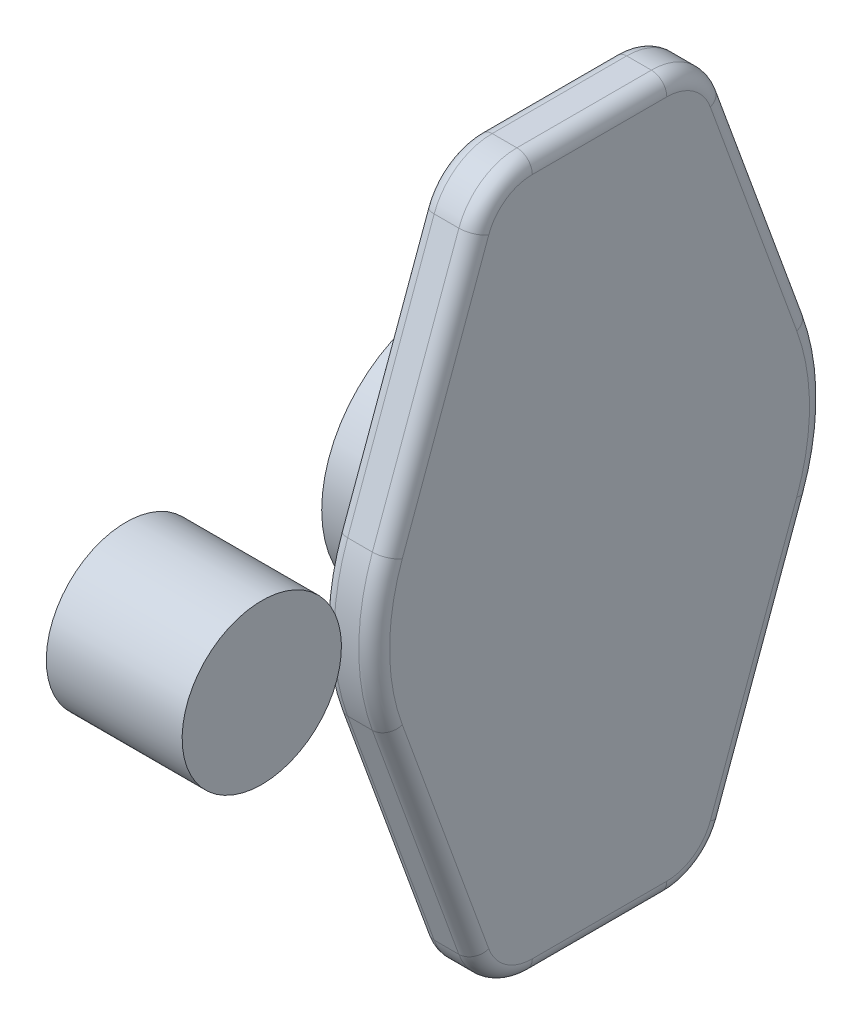
from build123d import *

# Parameters (mm, degrees)
SKETCH1_W           = 22
SKETCH1_H           = 12.9
SKETCH2_R           = 3.71375
CUT_EXTRUDE1_DEPTH  = 7.5725
BOSS_EXTRUDE1_DEPTH = 4.25
FILLET3_R           = 2.5
SKETCH8_R           = 20
SKETCH8_R_2         = 12.9
BOSS_EXTRUDE2_DEPTH = 16.5
FILLET4_R           = 2


with BuildPart() as part:
    # Sketch1 → Revolve1 (revolve)
    with BuildSketch(Plane.XY):
        with Locations((19.255, 6.45)):
            Rectangle(SKETCH1_W, SKETCH1_H)
    revolve(axis=Axis((8.255, 0, 0), (1, 0, 0)))

    # Sketch2 → Cut-Extrude1 (cut)
    with BuildSketch(Plane.ZY.offset(-8.255)):
        Circle(SKETCH2_R)
    extrude(amount=-CUT_EXTRUDE1_DEPTH, mode=Mode.SUBTRACT)


with BuildPart() as body_2:
    # Body-Move/Copy1: copy of part
    add(part.part.moved(Location((0, 0, 50.452769062))))


with BuildPart() as part_1:
    add(part.part)

    # Sketch6 → Boss-Extrude1 (add, symmetric)
    with BuildSketch(Plane(origin=(30.255, 0, 0), x_dir=(0, 0, -1), z_dir=(1, 0, 0))):
        with BuildLine():
            Line((10.891481178, -57.5), (-10.891481178, -57.5))
            ThreePointArc((-10.891481178, -57.5), (-16.625302969, -55.692880304), (-20.286784301, -50.924657534))
            Line((-20.286784301, -50.924657534), (-34.292856399, -12.5))
            ThreePointArc((-34.292856399, -12.5), (-36.5, 0), (-34.292856399, 12.5))
            Line((-34.292856399, 12.5), (-20.286784301, 50.924657534))
            ThreePointArc((-20.286784301, 50.924657534), (-16.625302969, 55.692880304), (-10.891481178, 57.5))
            Line((-10.891481178, 57.5), (10.891481178, 57.5))
            ThreePointArc((10.891481178, 57.5), (16.625302969, 55.692880304), (20.286784301, 50.924657534))
            Line((20.286784301, 50.924657534), (34.292856399, 12.5))
            ThreePointArc((34.292856399, 12.5), (36.5, 0), (34.292856399, -12.5))
            Line((34.292856399, -12.5), (20.286784301, -50.924657534))
            ThreePointArc((20.286784301, -50.924657534), (16.625302969, -55.692880304), (10.891481178, -57.5))
        make_face()
    extrude(amount=BOSS_EXTRUDE1_DEPTH, both=True)

    # Fillet3
    fillet3_edges = [part_1.edges().sort_by_distance(p)[0] for p in [
        (34.505, -31.712328767, -27.28982035),
        (34.505, 55.692880304, 16.625302969),
        (34.505, 31.712328767, 27.28982035),
        (34.505, -57.5, 0),
        (34.505, -55.692880304, -16.625302969),
        (34.505, 0, -36.5),
        (34.505, 31.712328767, -27.28982035),
        (34.505, 55.692880304, -16.625302969),
        (34.505, 57.5, 0),
        (34.505, 0, 36.5),
        (34.505, -31.712328767, 27.28982035),
        (34.505, -55.692880304, 16.625302969),
    ]]
    fillet(fillet3_edges, radius=FILLET3_R)

    # Sketch8 → Boss-Extrude2 (add)
    with BuildSketch(Plane.ZY.offset(-26.005)):
        Circle(SKETCH8_R)
        Circle(SKETCH8_R_2, mode=Mode.SUBTRACT)
    extrude(amount=BOSS_EXTRUDE2_DEPTH)

    # Fillet4
    fillet4_edges = [part_1.edges().sort_by_distance(p)[0] for p in [
        (26.005, 0, -36.5),
        (26.005, 31.712328767, -27.28982035),
        (26.005, 55.692880304, -16.625302969),
        (26.005, 57.5, 0),
        (26.005, 0, 36.5),
        (26.005, -31.712328767, 27.28982035),
        (26.005, -55.692880304, 16.625302969),
        (26.005, -31.712328767, -27.28982035),
        (26.005, -55.692880304, -16.625302969),
        (26.005, -57.5, 0),
        (26.005, 31.712328767, 27.28982035),
        (26.005, 55.692880304, 16.625302969),
        (26.005, 0, -20),
    ]]
    fillet(fillet4_edges, radius=FILLET4_R)


solid = Compound([body_2.part, part_1.part])
